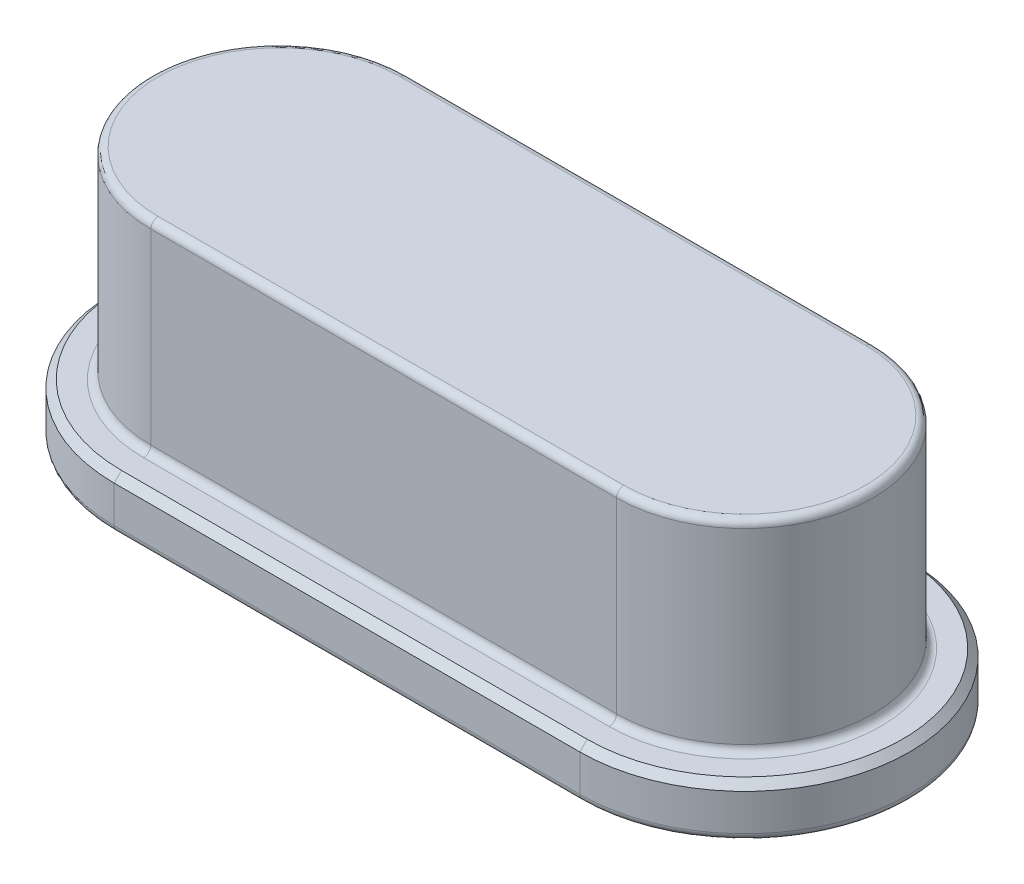
from build123d import *

# Parameters (mm, degrees)
BOSS_EXTRU_1_DEPTH = 0.7
BOSS_EXTRU_2_DEPTH = 2.75
CONG_1_R           = 0.1
CONG_2_R           = 0.1
CONG_3_R           = 0.1
CHANFREIN1_SIZE    = 0.1


with BuildPart() as part:
    # Esquisse1 → Boss.-Extru.1 (new body)
    with BuildSketch(Plane(origin=(0, 0, 0), x_dir=(1, 0, 0), z_dir=(0, 1, 0))):
        with BuildLine():
            Line((0, 2.25), (6.35, 2.25))
            ThreePointArc((6.35, 2.25), (8.6, 0), (6.35, -2.25))
            Line((6.35, -2.25), (0, -2.25))
            ThreePointArc((0, -2.25), (-2.25, 0), (0, 2.25))
        make_face()
    extrude(amount=BOSS_EXTRU_1_DEPTH)

    # Esquisse2 → Boss.-Extru.2 (add)
    with BuildSketch(Plane(origin=(0, 0.7, 0), x_dir=(1, 0, 0), z_dir=(0, 1, 0))):
        with BuildLine():
            Line((0, 1.75), (6.35, 1.75))
            ThreePointArc((6.35, 1.75), (8.1, 0), (6.35, -1.75))
            Line((6.35, -1.75), (0, -1.75))
            ThreePointArc((0, -1.75), (-1.75, 0), (0, 1.75))
        make_face()
    extrude(amount=BOSS_EXTRU_2_DEPTH)

    # Congé1
    cong_1_edges = [part.edges().sort_by_distance(p)[0] for p in [
        (-1.75, 0.7, 0),
        (3.175, 0.7, 1.75),
        (8.1, 0.7, 0),
        (3.175, 0.7, -1.75),
    ]]
    fillet(cong_1_edges, radius=CONG_1_R)

    # Congé2
    cong_2_edges = [part.edges().sort_by_distance(p)[0] for p in [
        (-1.75, 3.45, 0),
        (3.175, 3.45, 1.75),
        (8.1, 3.45, 0),
        (3.175, 3.45, -1.75),
    ]]
    fillet(cong_2_edges, radius=CONG_2_R)

    # Congé3
    cong_3_edges = [part.edges().sort_by_distance(p)[0] for p in [
        (3.175, 0, -2.25),
        (8.6, 0, 0),
        (3.175, 0, 2.25),
        (-2.25, 0, 0),
    ]]
    fillet(cong_3_edges, radius=CONG_3_R)

    # Chanfrein1
    chanfrein1_edges = [part.edges().sort_by_distance(p)[0] for p in [
        (8.6, 0.7, 0),
        (3.175, 0.7, -2.25),
        (-2.25, 0.7, 0),
        (3.175, 0.7, 2.25),
    ]]
    chamfer(chanfrein1_edges, length=CHANFREIN1_SIZE)


solid = part.part
